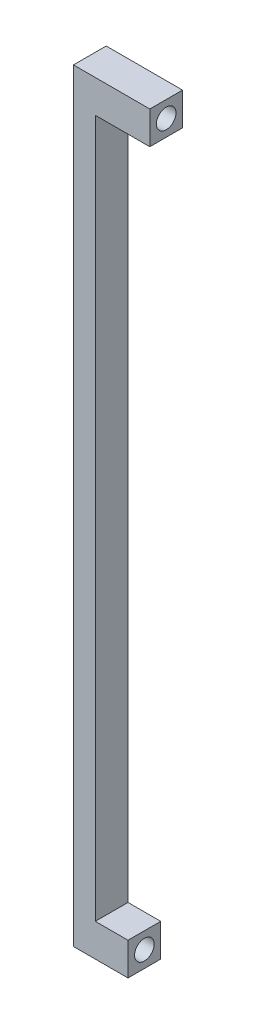
from build123d import *

# Parameters (mm, degrees)
CROQUIS1_W                       = 10
CROQUIS1_H                       = 6
CROQUIS1_W_2                     = 4
CROQUIS1_H_2                     = 140
CROQUIS1_W_3                     = 6
SALIENTE_EXTRUIR1_DEPTH          = 6
TALADRO_DE_MARGEN_PARA_M31_D     = 3.6
TALADRO_DE_MARGEN_PARA_M31_DEPTH = 3
TALADRO_DE_MARGEN_PARA_M31_TIP   = 1.081549114
TALADRO_DE_MARGEN_PARA_M32_D     = 3.6
TALADRO_DE_MARGEN_PARA_M32_DEPTH = 8.6
TALADRO_DE_MARGEN_PARA_M32_TIP   = 1.081549114


with BuildPart() as part:
    # Croquis1 → Saliente-Extruir1 (new body)
    with BuildSketch(Plane.XY):
        with Locations((9, 137)):
            Rectangle(CROQUIS1_W, CROQUIS1_H)
        with Locations((2, 70)):
            Rectangle(CROQUIS1_W_2, CROQUIS1_H_2)
        with Locations((7, 3)):
            Rectangle(CROQUIS1_W_3, CROQUIS1_H)
    extrude(amount=SALIENTE_EXTRUIR1_DEPTH)

    # Taladro de margen para M31
    with Locations(Plane(origin=(14, 0, 0), x_dir=(0, 0, -1), z_dir=(1, 0, 0))):
        with Locations((-3, 137)):
            Hole(TALADRO_DE_MARGEN_PARA_M31_D / 2, depth=TALADRO_DE_MARGEN_PARA_M31_DEPTH)
            with Locations((0, 0, -(TALADRO_DE_MARGEN_PARA_M31_DEPTH + TALADRO_DE_MARGEN_PARA_M31_TIP / 2))):  # 118° drill point
                Cone(0, TALADRO_DE_MARGEN_PARA_M31_D / 2, TALADRO_DE_MARGEN_PARA_M31_TIP, mode=Mode.SUBTRACT)

    # Taladro de margen para M32
    with Locations(Plane(origin=(10, 0, 0), x_dir=(0, 0, -1), z_dir=(1, 0, 0))):
        with Locations((-3, 3)):
            Hole(TALADRO_DE_MARGEN_PARA_M32_D / 2, depth=TALADRO_DE_MARGEN_PARA_M32_DEPTH)
            with Locations((0, 0, -(TALADRO_DE_MARGEN_PARA_M32_DEPTH + TALADRO_DE_MARGEN_PARA_M32_TIP / 2))):  # 118° drill point
                Cone(0, TALADRO_DE_MARGEN_PARA_M32_D / 2, TALADRO_DE_MARGEN_PARA_M32_TIP, mode=Mode.SUBTRACT)


solid = part.part
